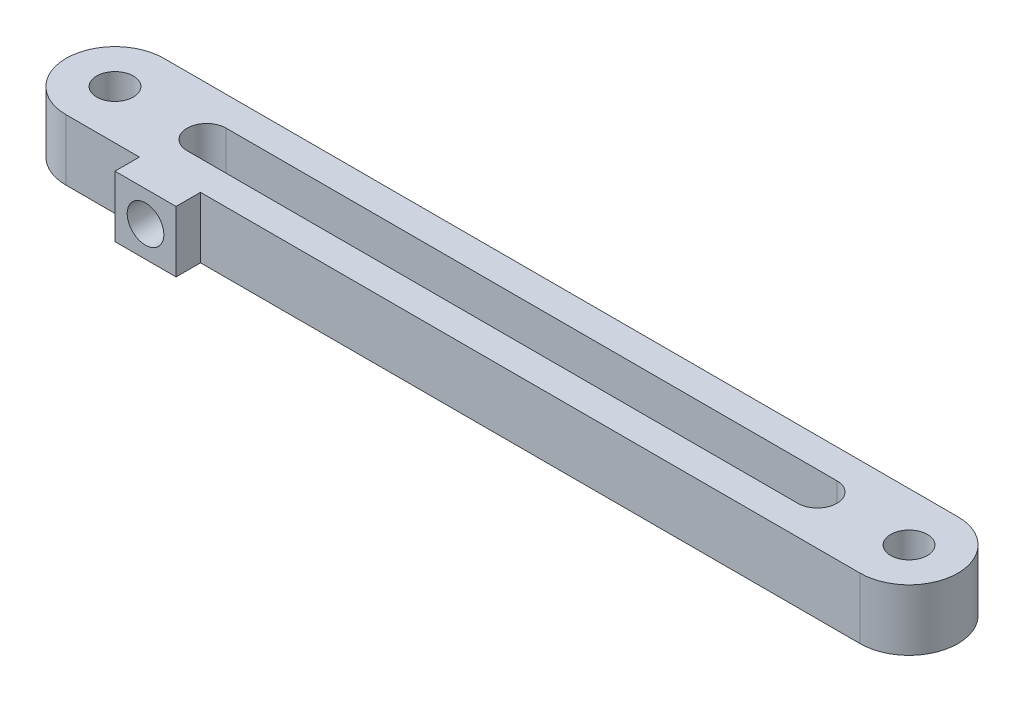
from build123d import *

# Parameters (mm, degrees)
SKETCH1_R           = 1.5
BOSS_EXTRUDE1_DEPTH = 5
SKETCH2_W           = 5
SKETCH2_H           = 5
BOSS_EXTRUDE2_DEPTH = 2
SKETCH3_R           = 1.5
CUT_EXTRUDE2_DEPTH  = 3


with BuildPart() as part:
    # Sketch1 → Boss-Extrude1 (new body)
    with BuildSketch(Plane(origin=(0, 0, 0), x_dir=(1, 0, 0), z_dir=(0, 1, 0))):
        with BuildLine():
            Line((-32.5, 4), (32.5, 4))
            ThreePointArc((32.5, 4), (36.5, 0), (32.5, -4))
            Line((32.5, -4), (-32.5, -4))
            ThreePointArc((-32.5, -4), (-36.5, 0), (-32.5, 4))
        make_face()
        with Locations((-32.5, 0)):
            Circle(SKETCH1_R, mode=Mode.SUBTRACT)
        with Locations((32.5, 0)):
            Circle(SKETCH1_R, mode=Mode.SUBTRACT)
        with BuildLine():
            Line((-25, 1.6), (25, 1.6))
            ThreePointArc((25, 1.6), (26.6, 0), (25, -1.6))
            Line((25, -1.6), (-25, -1.6))
            ThreePointArc((-25, -1.6), (-26.6, 0), (-25, 1.6))
        make_face(mode=Mode.SUBTRACT)
    extrude(amount=BOSS_EXTRUDE1_DEPTH)

    # Sketch2 → Boss-Extrude2 (add)
    with BuildSketch(Plane.XY.offset(4)):
        with Locations((-24, 2.5)):
            Rectangle(SKETCH2_W, SKETCH2_H)
    extrude(amount=BOSS_EXTRUDE2_DEPTH)

    # Sketch3 → Cut-Extrude2 (cut)
    with BuildSketch(Plane.XY.offset(6)):
        with Locations((-24, 2.5)):
            Circle(SKETCH3_R)
    extrude(amount=-CUT_EXTRUDE2_DEPTH, mode=Mode.SUBTRACT)


solid = part.part
